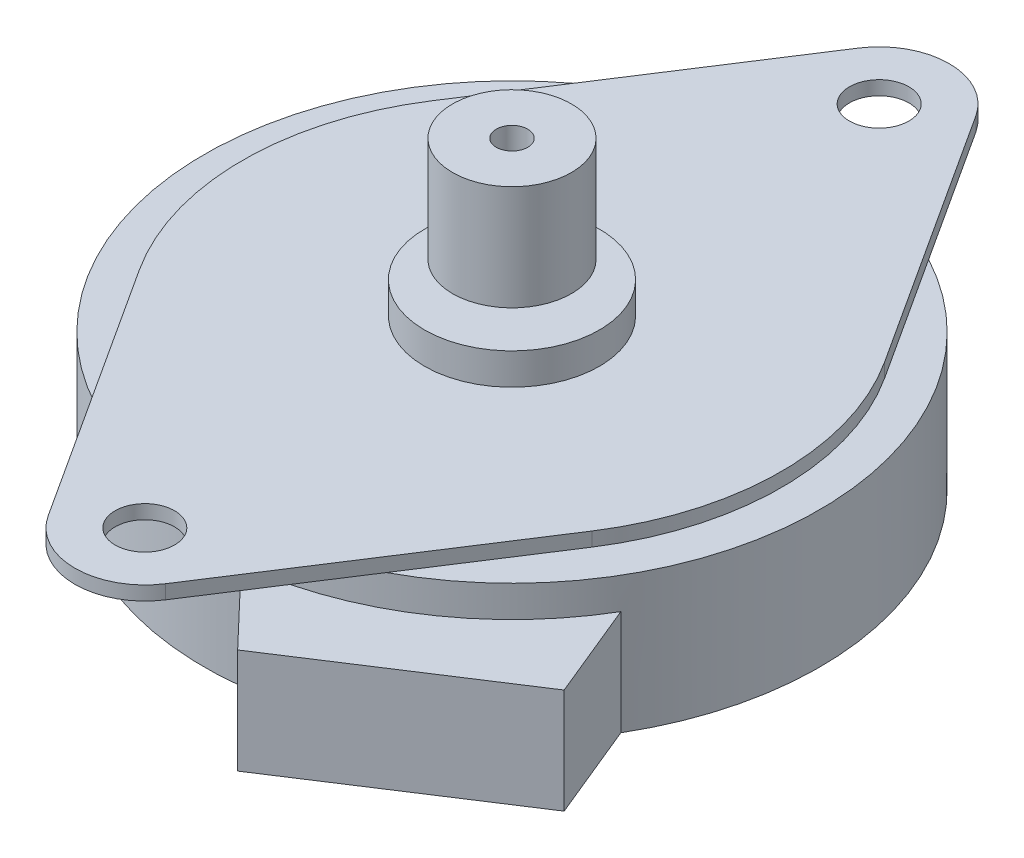
from build123d import *

# Parameters (mm, degrees)
SCHIZZO1_R                   = 17.6
ESTRUSIONE_ESTRUSIONE1_DEPTH = 7.8
SCHIZZO2_R                   = 1.7
ESTRUSIONE_ESTRUSIONE2_DEPTH = 0.8
SCHIZZO3_R                   = 5
ESTRUSIONE_ESTRUSIONE3_DEPTH = 1.8
SCHIZZO4_R                   = 0.9
ESTRUSIONE_ESTRUSIONE4_DEPTH = 5
SCHIZZO5_R                   = 2.6
ESTRUSIONE_ESTRUSIONE5_DEPTH = 0.5
ESTRUSIONE_ESTRUSIONE6_DEPTH = 6
EXTRUDE_START                = 1
SKETCH_1_R                   = 3.4
SKETCH_1_R_2                 = 0.9
EXTRUDE_1_DEPTH              = 6


with BuildPart() as part:
    # Schizzo1 → Estrusione-Estrusione1 (new body)
    with BuildSketch(Plane(origin=(0, 0, 0), x_dir=(1, 0, 0), z_dir=(0, 1, 0))):
        Circle(SCHIZZO1_R)
    extrude(amount=ESTRUSIONE_ESTRUSIONE1_DEPTH)

    # Schizzo2 → Estrusione-Estrusione2 (add)
    with BuildSketch(Plane(origin=(0, 7.8, 0), x_dir=(1, 0, 0), z_dir=(0, 1, 0))):
        with BuildLine():
            Line((-3.357806699, -23.173737374), (-12.937730964, -8.375475972))
            ThreePointArc((-12.937730964, -8.375475972), (-15.412121212, 0), (-12.937730964, 8.375475972))
            Line((-12.937730964, 8.375475972), (-3.357806699, 23.173737374))
            ThreePointArc((-3.357806699, 23.173737374), (0, 25), (3.357806699, 23.173737374))
            Line((3.357806699, 23.173737374), (12.937730964, 8.375475972))
            ThreePointArc((12.937730964, 8.375475972), (15.412121212, 0), (12.937730964, -8.375475972))
            Line((12.937730964, -8.375475972), (3.357806699, -23.173737374))
            ThreePointArc((3.357806699, -23.173737374), (0, -25), (-3.357806699, -23.173737374))
        make_face()
        with Locations((0, 21)):
            Circle(SCHIZZO2_R, mode=Mode.SUBTRACT)
        with Locations((0, -21)):
            Circle(SCHIZZO2_R, mode=Mode.SUBTRACT)
    extrude(amount=ESTRUSIONE_ESTRUSIONE2_DEPTH)

    # Schizzo3 → Estrusione-Estrusione3 (add)
    with BuildSketch(Plane(origin=(0, 8.6, 0), x_dir=(1, 0, 0), z_dir=(0, 1, 0))):
        Circle(SCHIZZO3_R)
    extrude(amount=ESTRUSIONE_ESTRUSIONE3_DEPTH)

    # Schizzo4 → Estrusione-Estrusione4 (add)
    with BuildSketch(Plane(origin=(0, 10.4, 0), x_dir=(1, 0, 0), z_dir=(0, 1, 0))):
        Circle(SCHIZZO4_R)
    extrude(amount=ESTRUSIONE_ESTRUSIONE4_DEPTH)

    # Schizzo5 → Estrusione-Estrusione5 (add)
    with BuildSketch(Plane.XZ):
        Circle(SCHIZZO5_R)
    extrude(amount=ESTRUSIONE_ESTRUSIONE5_DEPTH)

    # Schizzo6 → Estrusione-Estrusione6 (add)
    with BuildSketch(Plane.XZ):
        with BuildLine():
            Line((6.100676559, 21.792297849), (17.423572743, 14.440969942))
            Line((17.423572743, 14.440969942), (15.161900105, 8.937381339))
            ThreePointArc((15.161900105, 8.937381339), (9.583953419, 14.761701692), (1.993791209, 17.486703423))
            Line((1.993791209, 17.486703423), (6.100676559, 21.792297849))
        make_face()
    extrude(amount=-ESTRUSIONE_ESTRUSIONE6_DEPTH)

    # Эскиз1 → Бобышка-Вытянуть1 (add)
    with BuildSketch(Plane(origin=(0, 10.4, 0), x_dir=(1, 0, 0), z_dir=(0, 1, 0)).offset(EXTRUDE_START)):
        Circle(SKETCH_1_R)
        Circle(SKETCH_1_R_2, mode=Mode.SUBTRACT)
    extrude(amount=EXTRUDE_1_DEPTH)


solid = part.part
